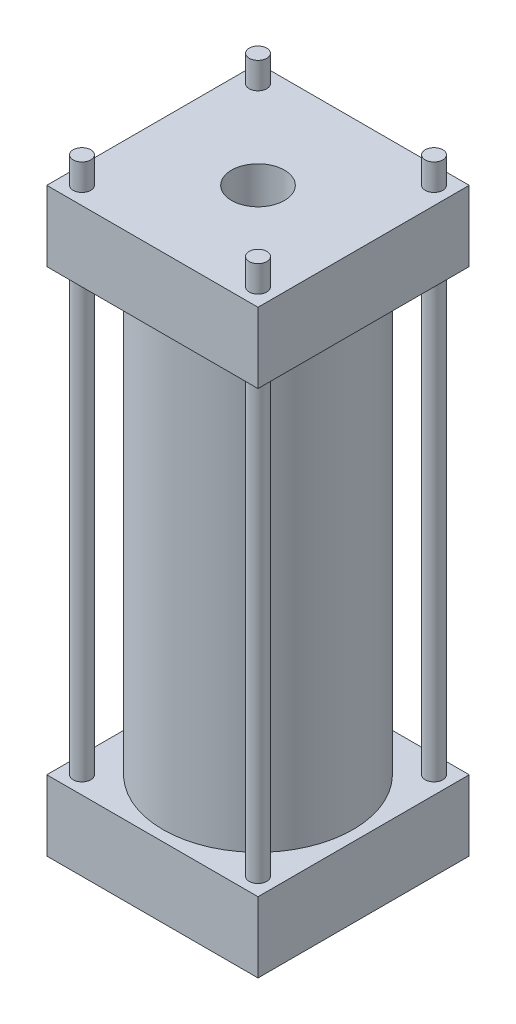
from build123d import *

# Parameters (mm, degrees)
SKETCH1_R            = 54
SKETCH1_R_2          = 50
BOSS_EXTRUDE1_DEPTH  = 250
SKETCH2_W            = 120
SKETCH2_H            = 120
BOSS_EXTRUDE2_DEPTH  = 40
SKETCH3_W            = 120
SKETCH3_H            = 120
BOSS_EXTRUDE3_DEPTH  = 40
CUT_EXTRUDE1_REACH   = 332
SKETCH4_R            = 15
BOSS_EXTRUDE4_START  = -295
SKETCH5_R            = 5
BOSS_EXTRUDE4_DEPTH  = 310
LPATTERN1_COUNT      = 2
LPATTERN1_PITCH      = 100
LPATTERN1_COUNT_DIR2 = 2
LPATTERN1_PITCH_DIR2 = 100


with BuildPart() as part:
    # Sketch1 → Boss-Extrude1 (new body)
    with BuildSketch(Plane(origin=(0, 0, 0), x_dir=(1, 0, 0), z_dir=(0, 1, 0))):
        Circle(SKETCH1_R)
        Circle(SKETCH1_R_2, mode=Mode.SUBTRACT)
    extrude(amount=BOSS_EXTRUDE1_DEPTH)

    # Sketch2 → Boss-Extrude2 (add)
    with BuildSketch(Plane.XZ):
        Rectangle(SKETCH2_W, SKETCH2_H)
    extrude(amount=BOSS_EXTRUDE2_DEPTH)

    # Sketch3 → Boss-Extrude3 (add)
    with BuildSketch(Plane(origin=(0, 250, 0), x_dir=(1, 0, 0), z_dir=(0, 1, 0))):
        Rectangle(SKETCH3_W, SKETCH3_H)
    extrude(amount=BOSS_EXTRUDE3_DEPTH)

    # Sketch4 → Cut-Extrude1 (cut, up to next)
    with BuildSketch(Plane(origin=(0, 290, 0), x_dir=(1, 0, 0), z_dir=(0, 1, 0)), mode=Mode.PRIVATE) as cut_extrude1_sk1:
        Circle(SKETCH4_R)
    cut_extrude1_tool1 = extrude(cut_extrude1_sk1.sketch, amount=-CUT_EXTRUDE1_REACH, mode=Mode.PRIVATE) & part.part
    add(cut_extrude1_tool1.solids().sort_by_distance((0, 290, 0))[0], mode=Mode.SUBTRACT)

    # Sketch5 → Boss-Extrude4 (add)
    with BuildSketch(Plane(origin=(0, 290, 0), x_dir=(1, 0, 0), z_dir=(0, 1, 0)).offset(BOSS_EXTRUDE4_START)):
        with Locations((-50, 50)):
            Circle(SKETCH5_R)
    boss_extrude4 = extrude(amount=BOSS_EXTRUDE4_DEPTH)

    # LPattern1: Boss-Extrude4 2 × 2
    with Locations(*[(i * LPATTERN1_PITCH, 0, j * LPATTERN1_PITCH_DIR2) for i in range(LPATTERN1_COUNT) for j in range(LPATTERN1_COUNT_DIR2) if (i, j) != (0, 0)]):
        add(boss_extrude4)


solid = part.part
